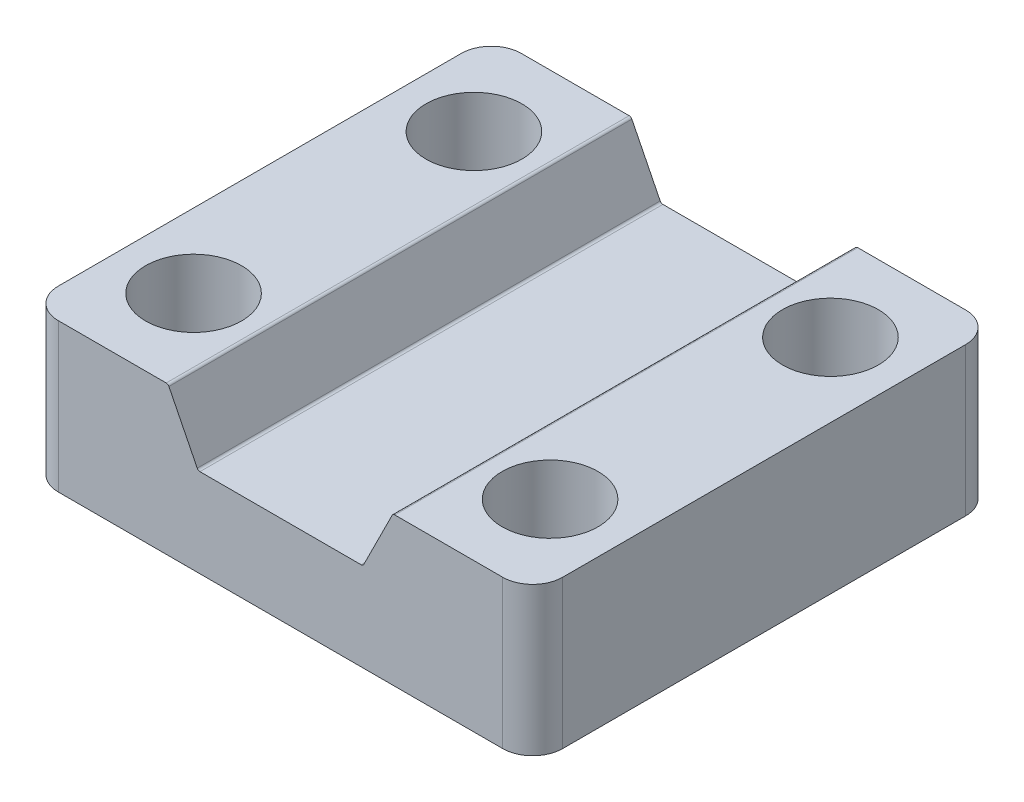
from build123d import *

# Parameters (mm, degrees)
SKETCH1_W               = 42.7228
SKETCH1_H               = 39.2176
SKETCH1_R               = 4.064
BOSS_EXTRUDE1_DEPTH     = 12.573
CUT_EXTRUDE1_DEPTH      = 1
CUT_EXTRUDE1_DEPTH_BACK = 40.2176
FILLET1_R               = 0.254
FILLET2_R               = 2.54


with BuildPart() as part:
    # Sketch1 → Boss-Extrude1 (new body)
    with BuildSketch(Plane(origin=(0, 0, 0), x_dir=(1, 0, 0), z_dir=(0, 1, 0))):
        Rectangle(SKETCH1_W, SKETCH1_H)
        with Locations((15.1003, -11.8745)):
            Circle(SKETCH1_R, mode=Mode.SUBTRACT)
        with Locations((-15.1003, 11.8745)):
            Circle(SKETCH1_R, mode=Mode.SUBTRACT)
        with Locations((15.1003, 11.8745)):
            Circle(SKETCH1_R, mode=Mode.SUBTRACT)
        with Locations((-15.1003, -11.8745)):
            Circle(SKETCH1_R, mode=Mode.SUBTRACT)
    extrude(amount=BOSS_EXTRUDE1_DEPTH)

    # Sketch2 → Cut-Extrude1 (cut, two sides)
    with BuildSketch(Plane.XY.offset(19.6088)) as cut_extrude1_sk:
        Polygon((-9.525, 12.573), (-6.985, 7.493), (6.985, 7.493), (9.525, 12.573), align=None)
    extrude(amount=CUT_EXTRUDE1_DEPTH, mode=Mode.SUBTRACT)
    extrude(cut_extrude1_sk.sketch, amount=-CUT_EXTRUDE1_DEPTH_BACK, mode=Mode.SUBTRACT)

    # Fillet1
    fillet1_edges = [part.edges().sort_by_distance(p)[0] for p in [
        (-9.525, 12.573, 0),
        (9.525, 12.573, 0),
        (6.985, 7.493, 0),
        (-6.985, 7.493, 0),
    ]]
    fillet(fillet1_edges, radius=FILLET1_R)

    # Fillet2
    fillet2_edges = [part.edges().sort_by_distance(p)[0] for p in [
        (21.3614, 6.2865, 19.6088),
        (-21.3614, 6.2865, 19.6088),
        (-21.3614, 6.2865, -19.6088),
        (21.3614, 6.2865, -19.6088),
    ]]
    fillet(fillet2_edges, radius=FILLET2_R)


solid = part.part
